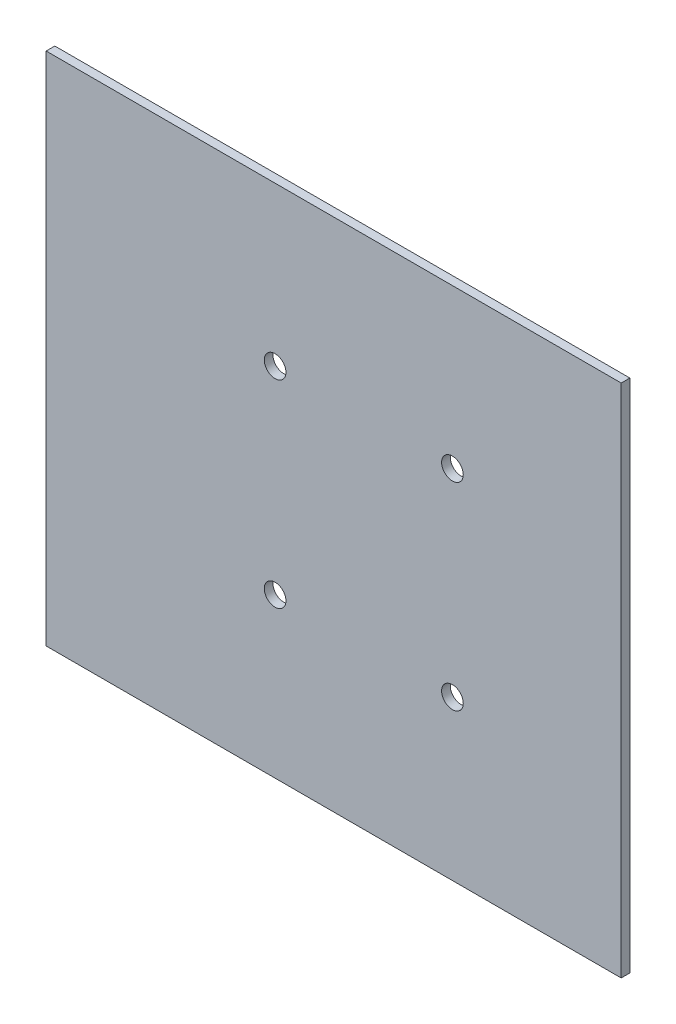
from build123d import *

# Parameters (mm, degrees)
ESQUISSE1_W             = 278.9
ESQUISSE1_H             = 249.9
BOSS_EXTRU_1_DEPTH      = 4.2
ESQUISSE4_R             = 5.25
ENL_V_MAT_EXTRU_3_DEPTH = 5


with BuildPart() as part:
    # Esquisse1 → Boss.-Extru.1 (new body)
    with BuildSketch(Plane.XY):
        with Locations((90.319800378, 94.175135181)):
            Rectangle(ESQUISSE1_W, ESQUISSE1_H)
    extrude(amount=BOSS_EXTRU_1_DEPTH)

    # Esquisse4 → Enlèv. mat.-Extru.3 (cut)
    with BuildSketch(Plane.XY.offset(4.2)):
        with Locations((61.919800378, 142.275135181)):
            Circle(ESQUISSE4_R)
        with Locations((61.919800378, 46.275135181)):
            Circle(ESQUISSE4_R)
        with Locations((147.919800378, 142.275135181)):
            Circle(ESQUISSE4_R)
        with Locations((147.919800378, 46.275135181)):
            Circle(ESQUISSE4_R)
    extrude(amount=-ENL_V_MAT_EXTRU_3_DEPTH, mode=Mode.SUBTRACT)


solid = part.part
